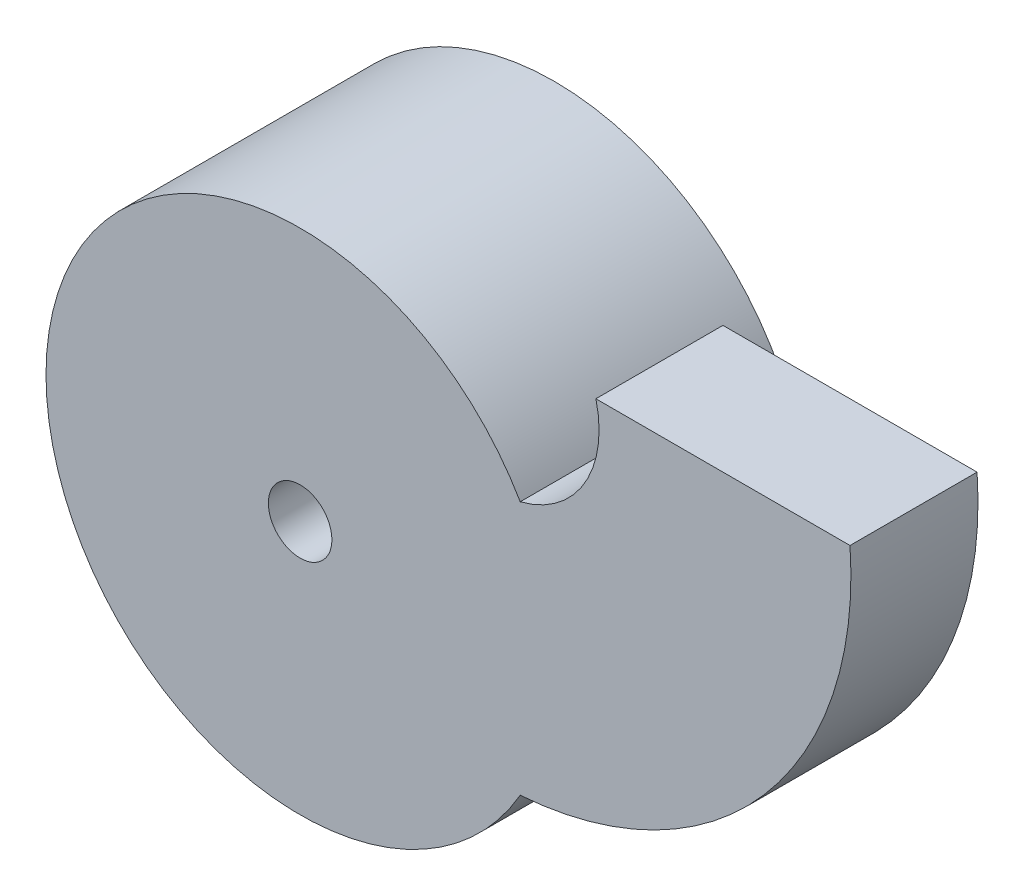
from build123d import *
from build123d.topology import SkipClean

# Parameters (mm, degrees)
SKETCH1_R           = 5
BOSS_EXTRUDE1_DEPTH = 20
SKETCH2_R           = 40
SKETCH2_R_2         = 5
BOSS_EXTRUDE2_DEPTH = 20


with BuildPart() as part:
    # Sketch1 → Boss-Extrude1 (new body)
    with BuildSketch(Plane.XY):
        with BuildLine():
            Line((0, 0), (40, 0))
            ThreePointArc((40, 0), (26.472356234, -40.750519772), (-11.908101275, -60))
            ThreePointArc((-11.908101275, -60), (-86.549117426, -40), (-11.908101275, -20))
            ThreePointArc((-11.908101275, -20), (-1.811915014, -12.466248525), (0, 0))
        make_face()
        with Locations((-46.549117426, -40)):
            Circle(SKETCH1_R, mode=Mode.SUBTRACT)
    extrude(amount=BOSS_EXTRUDE1_DEPTH)

    # Sketch2 → Boss-Extrude2 (add)
    with SkipClean():  # the faces are left unmerged after this step: merging them gives an invalid solid
        with BuildSketch(Plane(origin=(0, 0, 0), x_dir=(-1, 0, 0), z_dir=(0, 0, -1))):
            with Locations((46.549117426, -40)):
                Circle(SKETCH2_R)
            with Locations((46.549117426, -40)):
                Circle(SKETCH2_R_2, mode=Mode.SUBTRACT)
        extrude(amount=BOSS_EXTRUDE2_DEPTH)


solid = part.part
